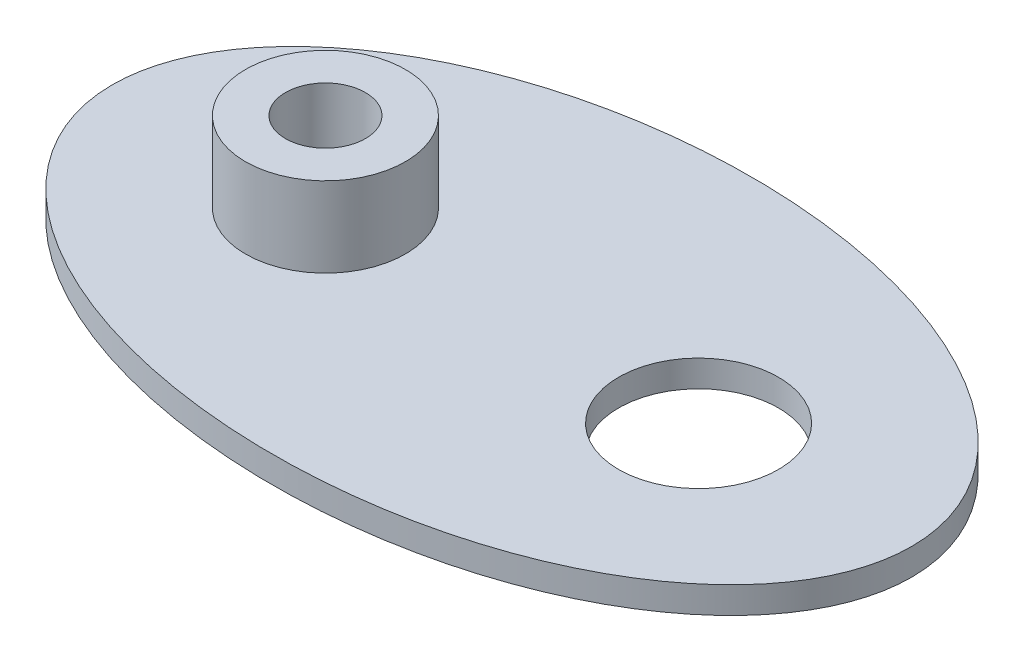
from build123d import *

# Parameters (mm, degrees)
CROQUIS1_RX             = 15
CROQUIS1_RY             = 9
CROQUIS1_R              = 3
SALIENTE_EXTRUIR1_DEPTH = 1
CROQUIS2_R              = 3
CROQUIS2_R_2            = 1.5
SALIENTE_EXTRUIR2_DEPTH = 3


with BuildPart() as part:
    # Croquis1 → Saliente-Extruir1 (new body)
    with BuildSketch(Plane(origin=(0, 0, 0), x_dir=(1, 0, 0), z_dir=(0, 1, 0))):
        with Locations(Location((0, 0), (0, 0, -180))):
            Ellipse(CROQUIS1_RX, CROQUIS1_RY)
        with Locations((-7, 0)):
            Circle(CROQUIS1_R, mode=Mode.SUBTRACT)
        with Locations((7, 0)):
            Circle(CROQUIS1_R, mode=Mode.SUBTRACT)
    extrude(amount=SALIENTE_EXTRUIR1_DEPTH)


with BuildPart() as body_2:
    # Croquis2 → Saliente-Extruir2 (new body)
    with BuildSketch(Plane(origin=(0, 1, 0), x_dir=(1, 0, 0), z_dir=(0, 1, 0))):
        with Locations((-7, 0)):
            Circle(CROQUIS2_R)
        with Locations((-7, 0)):
            Circle(CROQUIS2_R_2, mode=Mode.SUBTRACT)
    extrude(amount=SALIENTE_EXTRUIR2_DEPTH)


solid = Compound([part.part, body_2.part])
